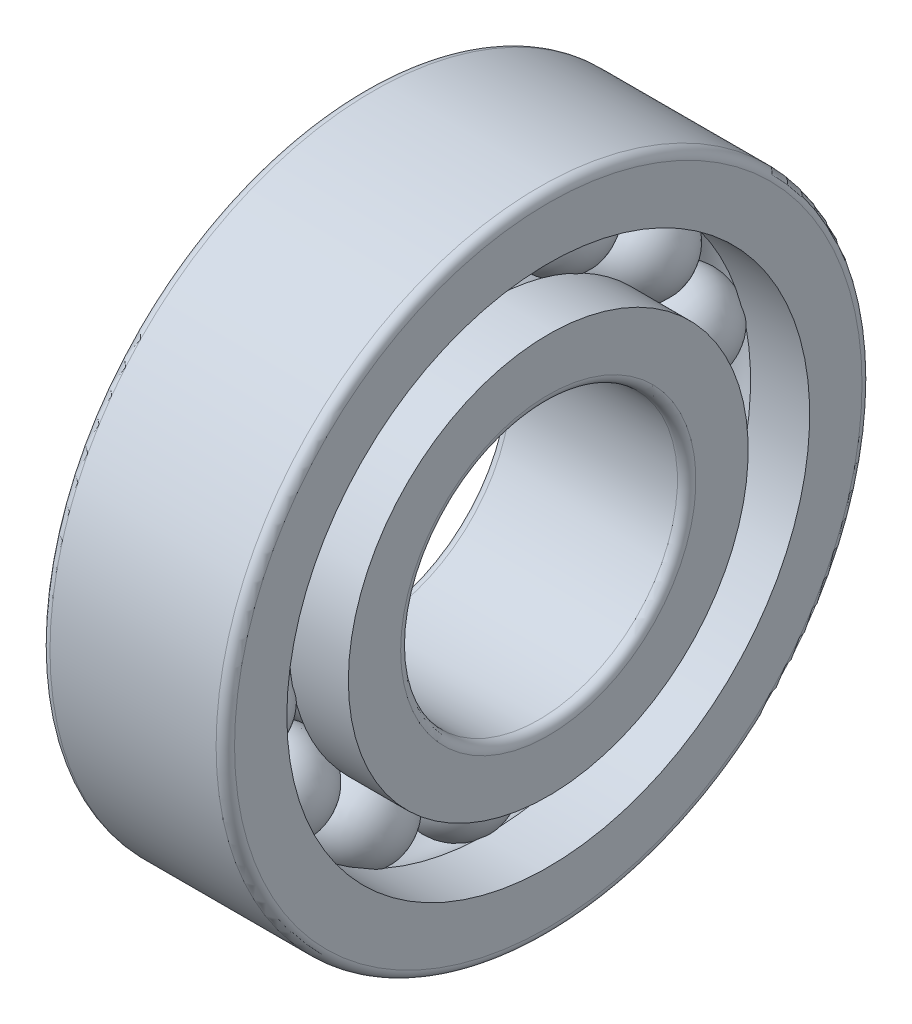
from build123d import *

# Parameters (mm, degrees)
CIRCULAR_PATTERN1_COUNT = 14
FILLET1_R               = 0.1


with BuildPart() as part:
    # Sketch1 → Revolve1 (revolve)
    with BuildSketch(Plane.XY):
        with BuildLine():
            Line((-0.5, 2.5), (0.5, 2.5))
            ThreePointArc((0.5, 2.5), (0, 3), (-0.5, 2.5))
        make_face()
    revolve1 = revolve(axis=Axis((-4.596601835, 2.5, 0), (1, 0, 0)))

    # Sketch2 → Revolve2 (revolve)
    with BuildSketch(Plane.XY, mode=Mode.PRIVATE) as revolve2_sk:
        with BuildLine():
            Line((-1, 2.166666667), (-1, 1.5))
            Line((-1, 1.5), (1, 1.5))
            Line((1, 1.5), (1, 2.166666667))
            Line((1, 2.166666667), (0.359150232, 2.166666667))
            ThreePointArc((0.359150232, 2.166666667), (0, 2.01), (-0.359150232, 2.166666667))
            Line((-0.359150232, 2.166666667), (-1, 2.166666667))
        make_face()
    revolve(revolve2_sk.sketch.rotate(Axis((-6.971390126, 0, 0), (1, 0, 0)), 90), axis=Axis((-6.971390126, 0, 0), (1, 0, 0)))

    # Sketch3 → Revolve3 (revolve)
    with BuildSketch(Plane.XY, mode=Mode.PRIVATE) as revolve3_sk:
        with BuildLine():
            Line((-1, 3.5), (1, 3.5))
            Line((1, 3.5), (1, 2.833333333))
            Line((1, 2.833333333), (0.359150232, 2.833333333))
            ThreePointArc((0.359150232, 2.833333333), (0, 2.99), (-0.359150232, 2.833333333))
            Line((-0.359150232, 2.833333333), (-1, 2.833333333))
            Line((-1, 2.833333333), (-1, 3.5))
        make_face()
    revolve(revolve3_sk.sketch.rotate(Axis((-8.710676495, 0, 0), (1, 0, 0)), 90), axis=Axis((-8.710676495, 0, 0), (1, 0, 0)))

    # Circular-Pattern1: Revolve1 ×14 about axis
    circular_pattern1_axis = Axis((0, 0, 0), (1, 0, 0))
    for i in range(1, CIRCULAR_PATTERN1_COUNT):
        add(revolve1.rotate(circular_pattern1_axis, i * 360 / CIRCULAR_PATTERN1_COUNT))

    # Fillet1
    fillet1_edges = [part.edges().sort_by_distance(p)[0] for p in [
        (-1, 0, -3.5),
        (1, 0, -3.5),
        (-1, 0, -1.5),
        (1, 0, -1.5),
    ]]
    fillet(fillet1_edges, radius=FILLET1_R)


solid = part.part
